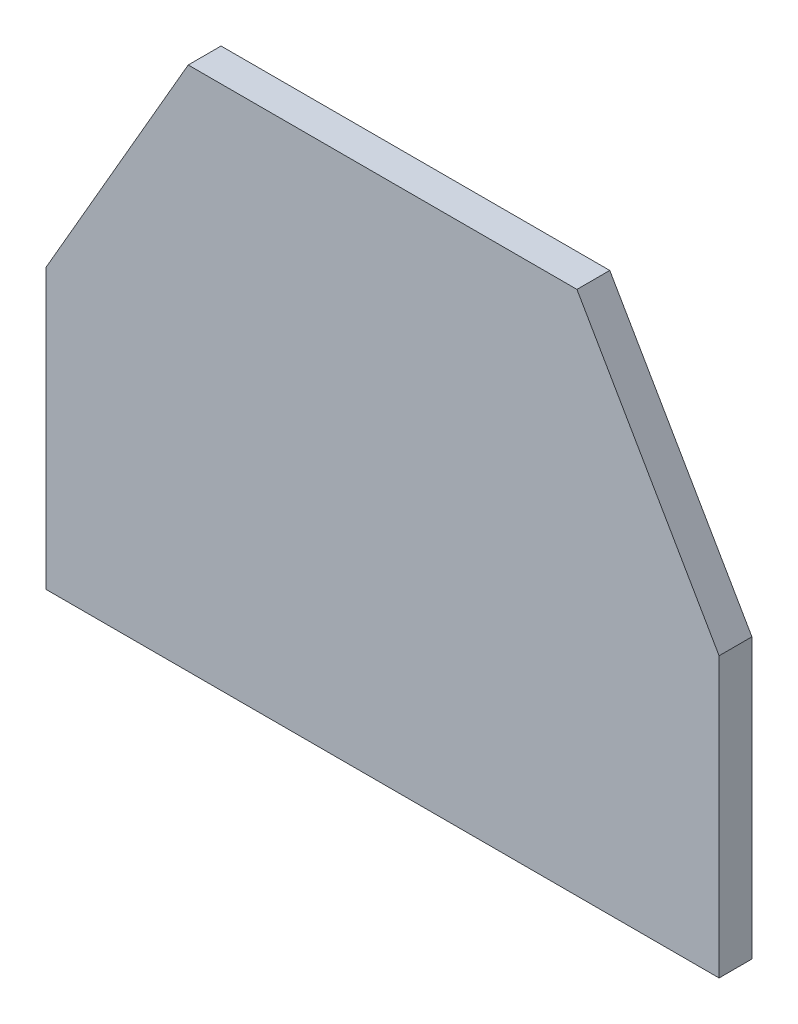
from build123d import *

# Parameters (mm, degrees)
BOSS_EXTRU_1_DEPTH = 20


with BuildPart() as part:
    # Esquisse1 → Boss.-Extru.1 (new body)
    with BuildSketch(Plane.XY):
        Polygon((236.807621582, 30), (0, 30), (-86.592378418, -120), (-86.592378418, -290), (323.407621582, -290), (323.407621582, -120), align=None)
    extrude(amount=BOSS_EXTRU_1_DEPTH)


solid = part.part
